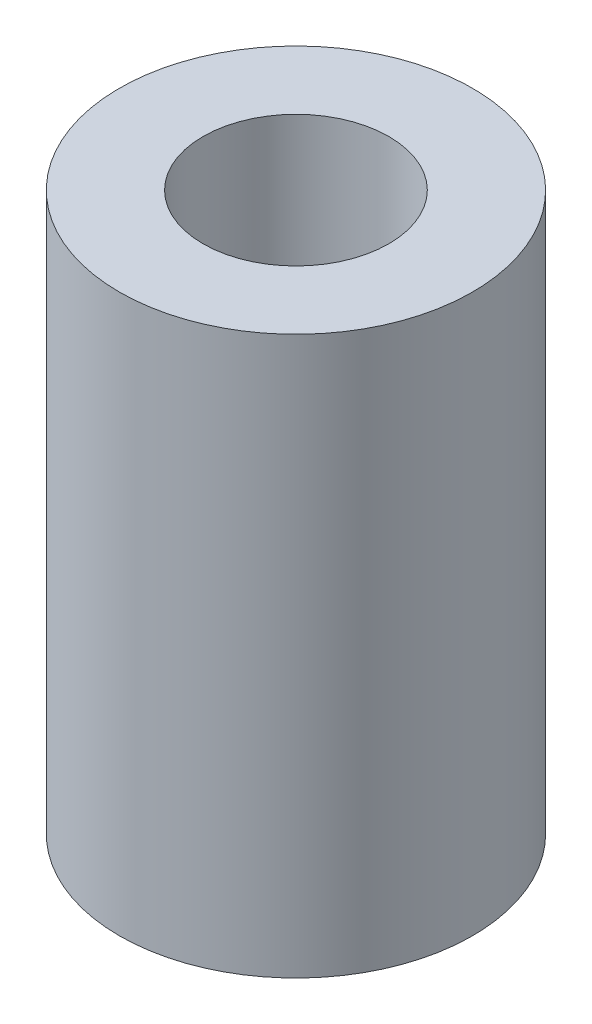
from build123d import *

# Parameters (mm, degrees)
SKETCH1_R           = 9.5
SKETCH1_R_2         = 5
BOSS_EXTRUDE1_DEPTH = 30


with BuildPart() as part:
    # Sketch1 → Boss-Extrude1 (new body)
    with BuildSketch(Plane(origin=(0, 0, 0), x_dir=(1, 0, 0), z_dir=(0, 1, 0))):
        Circle(SKETCH1_R)
        Circle(SKETCH1_R_2, mode=Mode.SUBTRACT)
    extrude(amount=BOSS_EXTRUDE1_DEPTH)


solid = part.part
